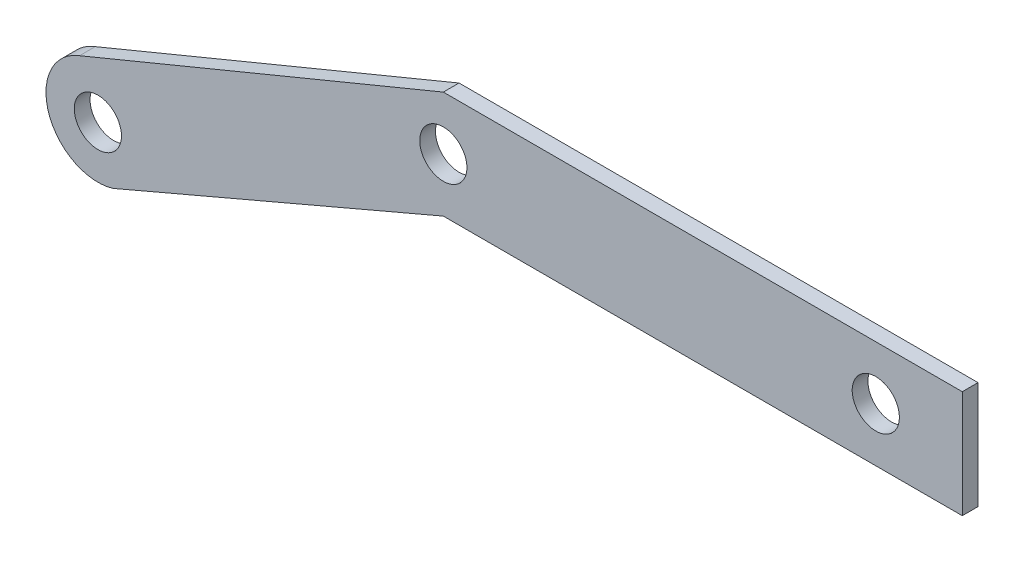
from build123d import *

# Parameters (mm, degrees)
MODEL_R                 = 1.5
SALIENTE_EXTRUIR1_DEPTH = 1


with BuildPart() as part:
    # Model → Saliente-Extruir1 (new body)
    with BuildSketch(Plane.XY):
        with BuildLine():
            Line((6.261217919, 18.769360839), (-14.739513879, 9.794996238))
            ThreePointArc((-14.739513879, 9.794996238), (-18.828558612, 11.883464999), (-16.872209477, 16.037341099))
            Line((-16.872209477, 16.037341099), (6.261217919, 25.600360839))
            Line((6.261217919, 25.600360839), (39.261217919, 25.600360839))
            Line((39.261217919, 25.600360839), (39.261217919, 18.769360839))
            Line((39.261217919, 18.769360839), (6.261217919, 18.769360839))
        make_face()
        with Locations((33.761217919, 22.184860839)):
            Circle(MODEL_R, mode=Mode.SUBTRACT)
        with Locations((6.261217919, 22.184860839)):
            Circle(MODEL_R, mode=Mode.SUBTRACT)
        with Locations((-15.705782081, 12.950360839)):
            Circle(MODEL_R, mode=Mode.SUBTRACT)
    extrude(amount=SALIENTE_EXTRUIR1_DEPTH)


solid = part.part
